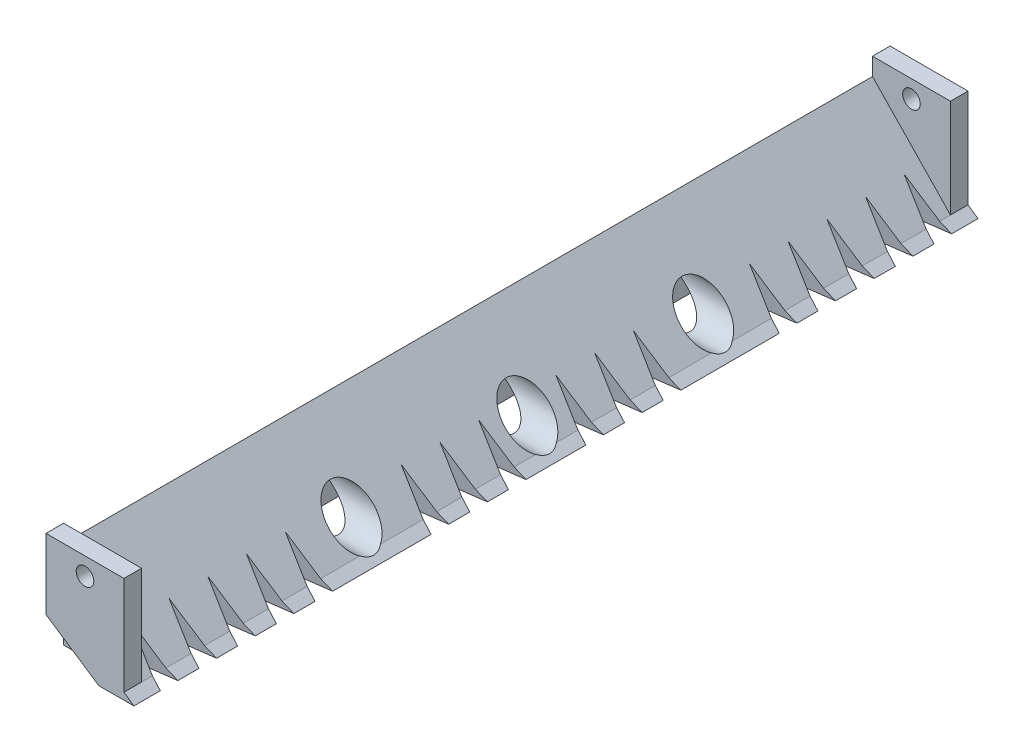
from build123d import *

# Parameters (mm, degrees)
BOSS_EXTRUDE1_DEPTH = 480
SKETCH2_R           = 5
BOSS_EXTRUDE2_DEPTH = 10
BOSS_EXTRUDE3_REACH = 482
CUT_EXTRUDE9_DEPTH  = 28
SKETCH14_W          = 460
SKETCH14_H          = 35
BOSS_EXTRUDE6_DEPTH = 5
SKETCH7_R           = 12.5
CUT_EXTRUDE8_DEPTH  = 56
SKETCH15_R          = 12.5
SKETCH15_R_2        = 9
BOSS_EXTRUDE7_DEPTH = 5


with BuildPart() as part:
    # Sketch1 → Boss-Extrude1 (new body)
    with BuildSketch(Plane.XY):
        Polygon((0, 0), (50, -35), (30, -35), (0, -15), align=None)
    extrude(amount=BOSS_EXTRUDE1_DEPTH)

    # Sketch2 → Boss-Extrude2 (add)
    with BuildSketch(Plane.XY.offset(480)):
        Polygon((0, -15), (0, 25), (44.349659334, 25), (44.349659334, -15), (44.349659334, -35), (30, -35), align=None)
        with Locations((22.174829667, 15)):
            Circle(SKETCH2_R, mode=Mode.SUBTRACT)
    boss_extrude2 = extrude(amount=-BOSS_EXTRUDE2_DEPTH)

    # Mirror1: Boss-Extrude2 across plane
    add(boss_extrude2.mirror(Plane.XY.offset(240)))

    # Sketch4 → Boss-Extrude3 (add, up to next)
    with BuildSketch(Plane.XY.offset(480), mode=Mode.PRIVATE) as boss_extrude3_sk1:
        Polygon((0, 0), (0, 15), (44.349659334, -31.044761534), align=None)
    boss_extrude3_tool1 = extrude(boss_extrude3_sk1.sketch, amount=-BOSS_EXTRUDE3_REACH, mode=Mode.PRIVATE) - part.part
    add(boss_extrude3_tool1.solids().sort_by_distance((14.78322, -5.348254, 480))[0])

    # Sketch3 → Cut-Extrude9 (cut, symmetric)
    with BuildSketch(Plane(origin=(0, 0, 0), x_dir=(0.819231921, -0.573462344, 0), z_dir=(0.573462344, 0.819231921, 0))):
        Polygon((61.032778079, -465), (31.032778079, -460), (61.032778079, -455), align=None)
        Polygon((61.032778079, -443), (31.032778079, -438), (61.032778079, -433), align=None)
        Polygon((61.032778079, -421), (31.032778079, -416), (61.032778079, -411), align=None)
        Polygon((61.032778079, -399), (31.032778079, -394), (61.032778079, -389), align=None)
        Polygon((61.032778079, -377), (31.032778079, -372), (61.032778079, -367), align=None)
        Polygon((61.032778079, -311), (31.032778079, -306), (61.032778079, -301), align=None)
        Polygon((61.032778079, -289), (31.032778079, -284), (61.032778079, -279), align=None)
        Polygon((61.032778079, -267), (31.032778079, -262), (61.032778079, -257), align=None)
        Polygon((61.032778079, -223), (31.032778079, -218), (61.032778079, -213), align=None)
        Polygon((61.032778079, -201), (31.032778079, -196), (61.032778079, -191), align=None)
        Polygon((61.032778079, -179), (31.032778079, -174), (61.032778079, -169), align=None)
        Polygon((61.032778079, -113), (31.032778079, -108), (61.032778079, -103), align=None)
        Polygon((61.032778079, -91), (31.032778079, -86), (61.032778079, -81), align=None)
        Polygon((61.032778079, -69), (31.032778079, -64), (61.032778079, -59), align=None)
        Polygon((61.032778079, -47), (31.032778079, -42), (61.032778079, -37), align=None)
        Polygon((61.032778079, -25), (31.032778079, -20), (61.032778079, -15), align=None)
    extrude(amount=CUT_EXTRUDE9_DEPTH, both=True, mode=Mode.SUBTRACT)

    # Sketch14 → Boss-Extrude6 (add)
    with BuildSketch(Plane.ZY):
        with Locations((240, -17.5)):
            Rectangle(SKETCH14_W, SKETCH14_H)
    extrude(amount=-BOSS_EXTRUDE6_DEPTH)

    # Sketch7 → Cut-Extrude8 (cut)
    with BuildSketch(Plane.ZY):
        with Locations((240, -20)):
            Circle(SKETCH7_R)
        with Locations((340, -20)):
            Circle(SKETCH7_R)
        with Locations((140, -20)):
            Circle(SKETCH7_R)
    extrude(amount=-CUT_EXTRUDE8_DEPTH, mode=Mode.SUBTRACT)

    # Sketch15 → Boss-Extrude7 (add)
    with BuildSketch(Plane.ZY):
        with Locations((340, -20)):
            Circle(SKETCH15_R)
        with Locations((340, -20)):
            Circle(SKETCH15_R_2, mode=Mode.SUBTRACT)
        with Locations((240, -20)):
            Circle(SKETCH15_R)
        with Locations((240, -20)):
            Circle(SKETCH15_R_2, mode=Mode.SUBTRACT)
        with Locations((140, -20)):
            Circle(SKETCH15_R)
        with Locations((140, -20)):
            Circle(SKETCH15_R_2, mode=Mode.SUBTRACT)
    extrude(amount=-BOSS_EXTRUDE7_DEPTH)


solid = part.part
